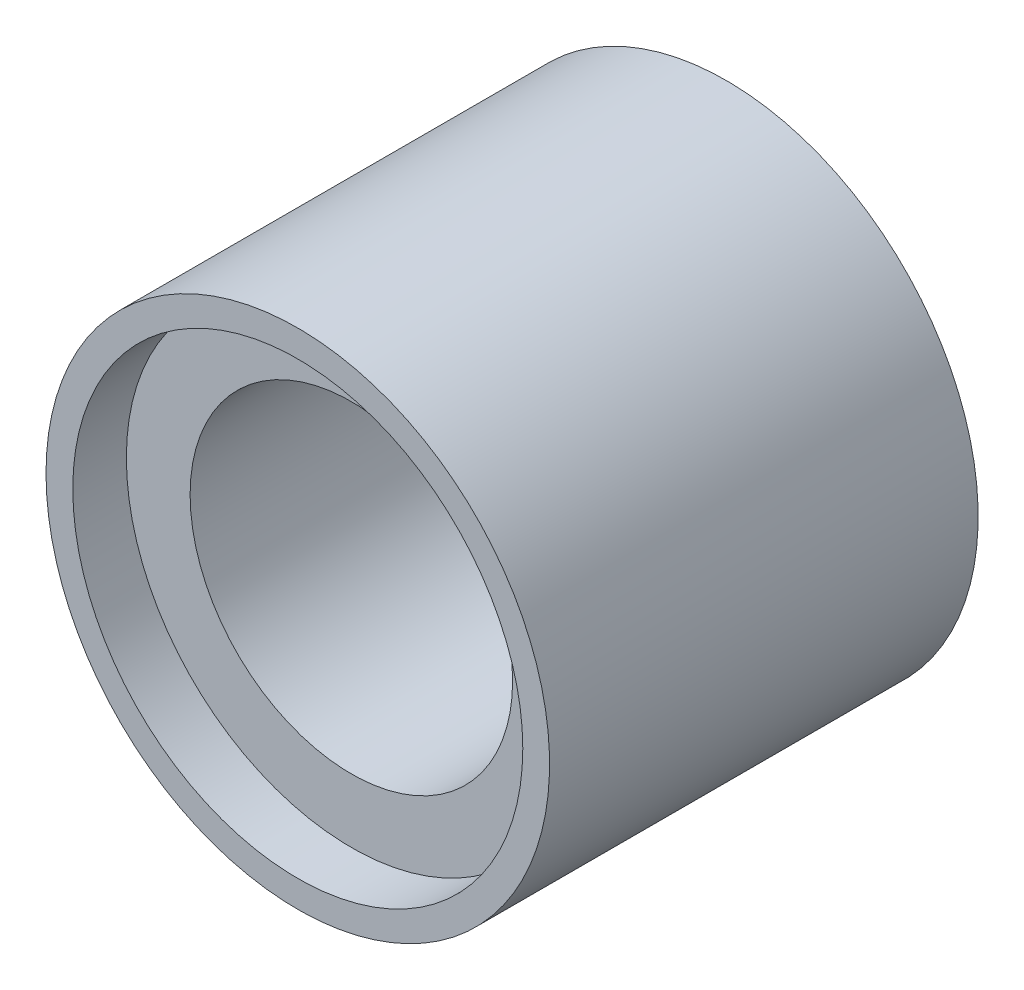
from build123d import *

# Parameters (mm, degrees)
SKETCH1_R           = 23.5
SKETCH1_R_2         = 15.05
BOSS_EXTRUDE1_DEPTH = 15
SKETCH2_R           = 23.5
SKETCH2_R_2         = 21
BOSS_EXTRUDE2_DEPTH = 5


with BuildPart() as part:
    # Sketch1 → Boss-Extrude1 (new body, symmetric)
    with BuildSketch(Plane.XY):
        Circle(SKETCH1_R)
        Circle(SKETCH1_R_2, mode=Mode.SUBTRACT)
    extrude(amount=BOSS_EXTRUDE1_DEPTH, both=True)

    # Sketch2 → Boss-Extrude2 (add)
    with BuildSketch(Plane(origin=(0, 0, -15), x_dir=(-1, 0, 0), z_dir=(0, 0, -1))):
        Circle(SKETCH2_R)
        Circle(SKETCH2_R_2, mode=Mode.SUBTRACT)
    boss_extrude2 = extrude(amount=BOSS_EXTRUDE2_DEPTH)

    # Mirror1: Boss-Extrude2 across plane
    add(boss_extrude2.mirror(Plane.XY))


solid = part.part
